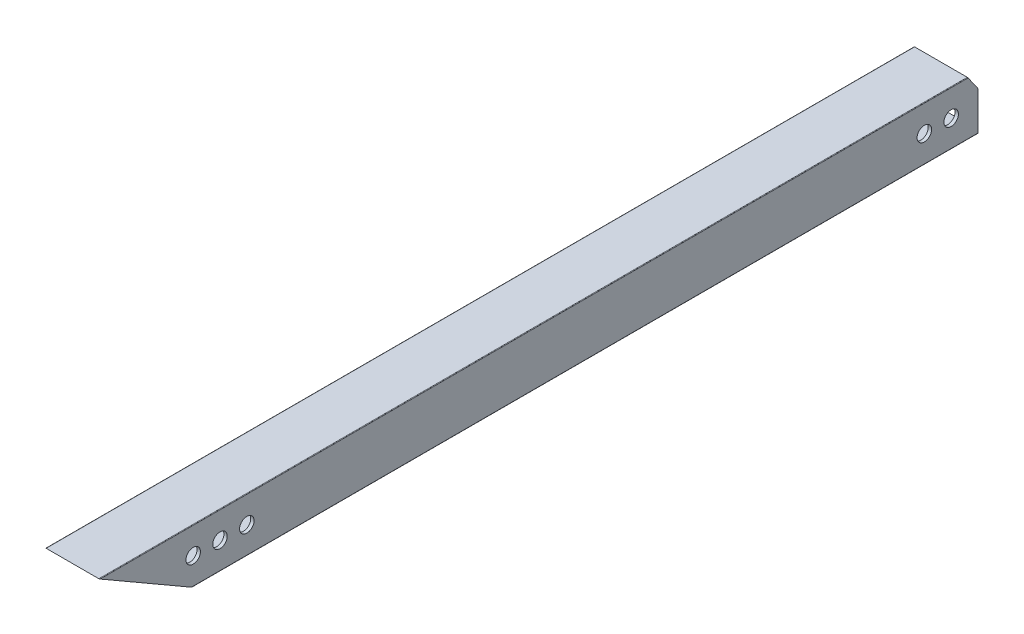
from build123d import *

# Parameters (mm, degrees)
BOSS_EXTRUDE1_DEPTH = 415.925
SKETCH2_R           = 3.429
CUT_EXTRUDE1_DEPTH  = 26.4


with BuildPart() as part:
    # Sketch1 → Boss-Extrude1 (new body)
    with BuildSketch(Plane.XY):
        with BuildLine():
            Line((-12.446, -12.7), (12.446, -12.7))
            ThreePointArc((12.446, -12.7), (12.625605122, -12.625605122), (12.7, -12.446))
            Line((12.7, -12.446), (12.7, 12.446))
            ThreePointArc((12.7, 12.446), (12.625605122, 12.625605122), (12.446, 12.7))
            Line((12.446, 12.7), (-12.446, 12.7))
            ThreePointArc((-12.446, 12.7), (-12.625605122, 12.625605122), (-12.7, 12.446))
            Line((-12.7, 12.446), (-12.7, -12.446))
            ThreePointArc((-12.7, -12.446), (-12.625605122, -12.625605122), (-12.446, -12.7))
        make_face()
        with BuildLine():
            Line((-11.1125, -9.5885), (-11.1125, 9.5885))
            ThreePointArc((-11.1125, 9.5885), (-10.666130735, 10.666130735), (-9.5885, 11.1125))
            Line((-9.5885, 11.1125), (9.5885, 11.1125))
            ThreePointArc((9.5885, 11.1125), (10.666130735, 10.666130735), (11.1125, 9.5885))
            Line((11.1125, 9.5885), (11.1125, -9.5885))
            ThreePointArc((11.1125, -9.5885), (10.666130735, -10.666130735), (9.5885, -11.1125))
            Line((9.5885, -11.1125), (-9.5885, -11.1125))
            ThreePointArc((-9.5885, -11.1125), (-10.666130735, -10.666130735), (-11.1125, -9.5885))
        make_face(mode=Mode.SUBTRACT)
    extrude(amount=BOSS_EXTRUDE1_DEPTH)

    # Sketch2 → Cut-Extrude1 (cut, through all)
    with BuildSketch(Plane.ZY.offset(12.7)):
        with Locations((371.475, 0)):
            Circle(SKETCH2_R)
        with Locations((358.775, 0)):
            Circle(SKETCH2_R)
        with Locations((346.075, 0)):
            Circle(SKETCH2_R)
        with Locations((12.7, 0)):
            Circle(SKETCH2_R)
        with Locations((25.4, 0)):
            Circle(SKETCH2_R)
        Polygon((415.925, 12.7), (371.930909488, -12.7), (415.925, -12.7), align=None)
        Polygon((0, 5.78069553), (4.844949149, 12.7), (0, 12.7), align=None)
    extrude(amount=-CUT_EXTRUDE1_DEPTH, mode=Mode.SUBTRACT)


solid = part.part
